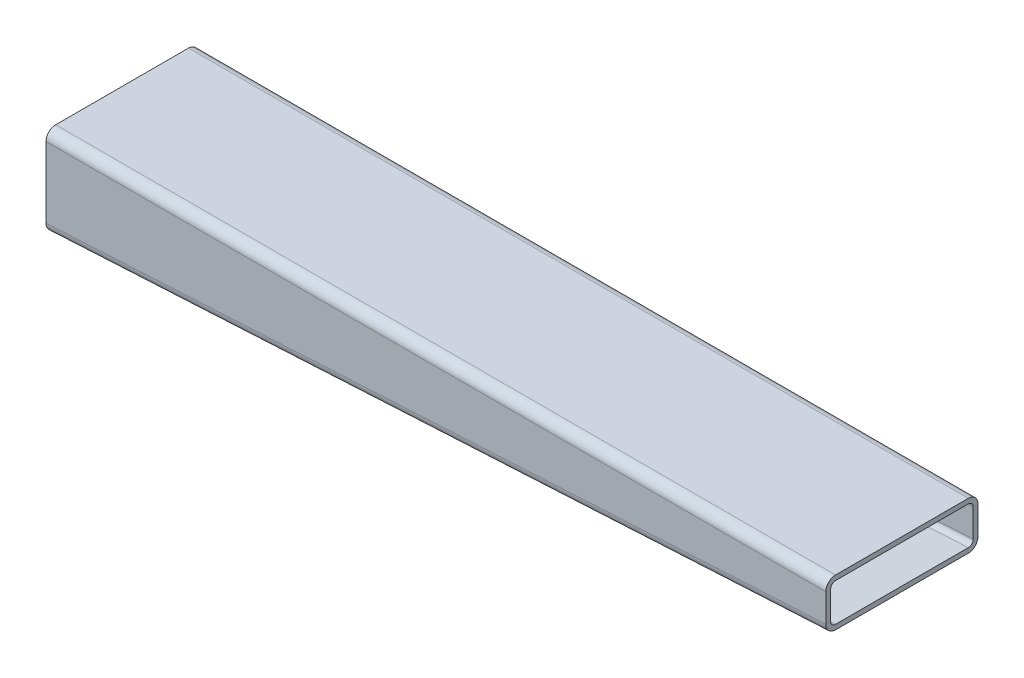
from build123d import *

# Parameters (mm, degrees)
SKETCH1_W           = 410
SKETCH1_H           = 80.00000002
BOSS_EXTRUDE1_DEPTH = 65
CUT_EXTRUDE1_DEPTH  = 96.52
FILLET1_R           = 5.08
FILLET2_R           = 5.08
FILLET3_R           = 5.08
FILLET4_R           = 5.08
SHELL2_T            = -2.54


with BuildPart() as part:
    # Sketch1 → Boss-Extrude1 (new body)
    with BuildSketch(Plane(origin=(0, 0, 0), x_dir=(1, 0, 0), z_dir=(0, 1, 0))):
        with Locations((201.324966403, -38.031873554)):
            Rectangle(SKETCH1_W, SKETCH1_H)
    extrude(amount=BOSS_EXTRUDE1_DEPTH)

    # Sketch3 → Cut-Extrude1 (cut)
    with BuildSketch(Plane.XY.offset(78.031873564)):
        Polygon((-3.675033597, 17.620000018), (406.324966403, 40), (452.471299635, -78.145402135), (-12.284026323, -65.583685792), (-43.531224316, 90.933184559), align=None)
    extrude(amount=-CUT_EXTRUDE1_DEPTH, mode=Mode.SUBTRACT)

    # Fillet1
    fillet1_edges = [part.edges().sort_by_distance(p)[0] for p in [
        (201.324966403, 65, 78.031873564),
    ]]
    fillet(fillet1_edges, radius=FILLET1_R)

    # Fillet2
    fillet2_edges = [part.edges().sort_by_distance(p)[0] for p in [
        (201.324966403, 28.810000009, 78.031873564),
    ]]
    fillet(fillet2_edges, radius=FILLET2_R)

    # Fillet3
    fillet3_edges = [part.edges().sort_by_distance(p)[0] for p in [
        (201.324966403, 65, -1.968126456),
    ]]
    fillet(fillet3_edges, radius=FILLET3_R)

    # Fillet4
    fillet4_edges = [part.edges().sort_by_distance(p)[0] for p in [
        (201.324966403, 28.810000009, -1.968126456),
    ]]
    fillet(fillet4_edges, radius=FILLET4_R)

    # Shell2
    shell2_openings = [part.faces().sort_by_distance(p)[0] for p in [
        (406.324966403, 52.501499056, 38.031873554),
    ]]
    offset(amount=SHELL2_T, openings=shell2_openings, kind=Kind.INTERSECTION)


solid = part.part
